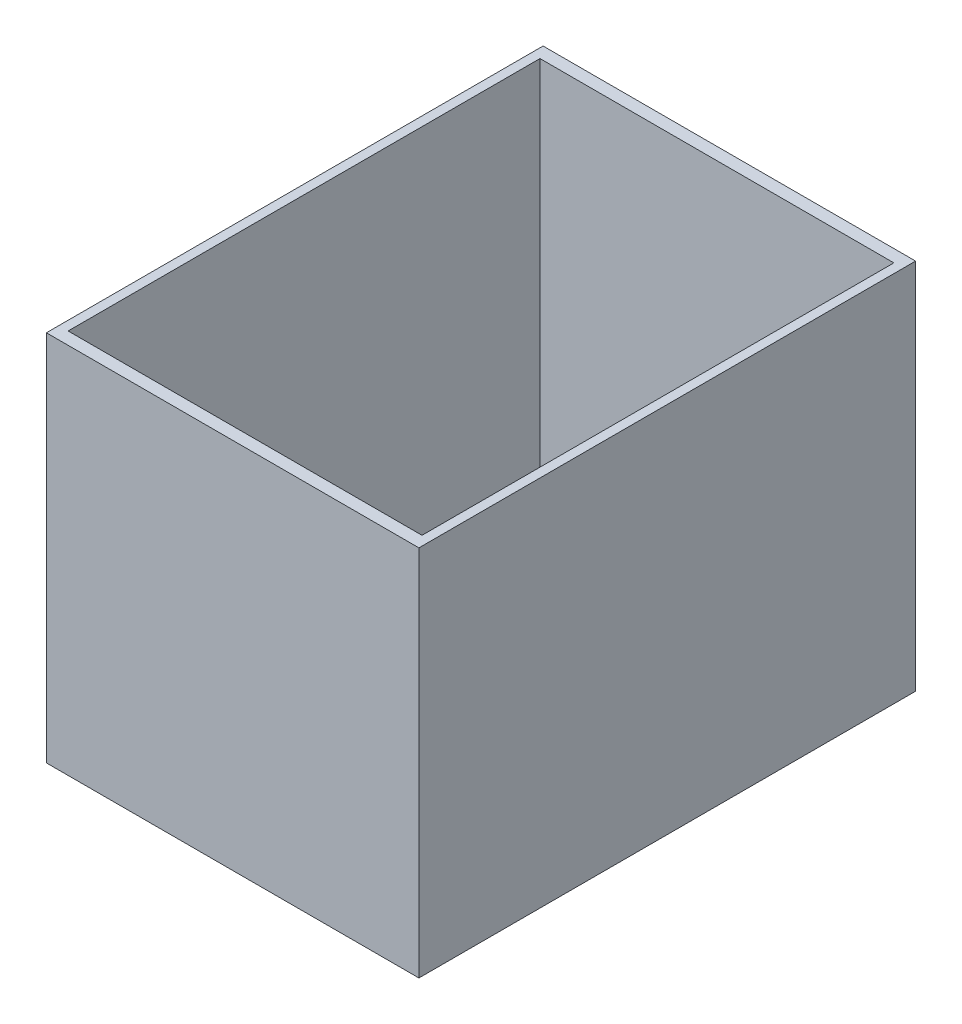
from build123d import *

# Parameters (mm, degrees)
SKETCH1_W           = 30
SKETCH1_H           = 40
SKETCH1_W_2         = 28.5
SKETCH1_H_2         = 38
BOSS_EXTRUDE1_DEPTH = 30


with BuildPart() as part:
    # Sketch1 → Boss-Extrude1 (new body)
    with BuildSketch(Plane(origin=(0, 0, 0), x_dir=(1, 0, 0), z_dir=(0, 1, 0))):
        Rectangle(SKETCH1_W, SKETCH1_H)
        Rectangle(SKETCH1_W_2, SKETCH1_H_2, mode=Mode.SUBTRACT)
    extrude(amount=BOSS_EXTRUDE1_DEPTH)


solid = part.part
